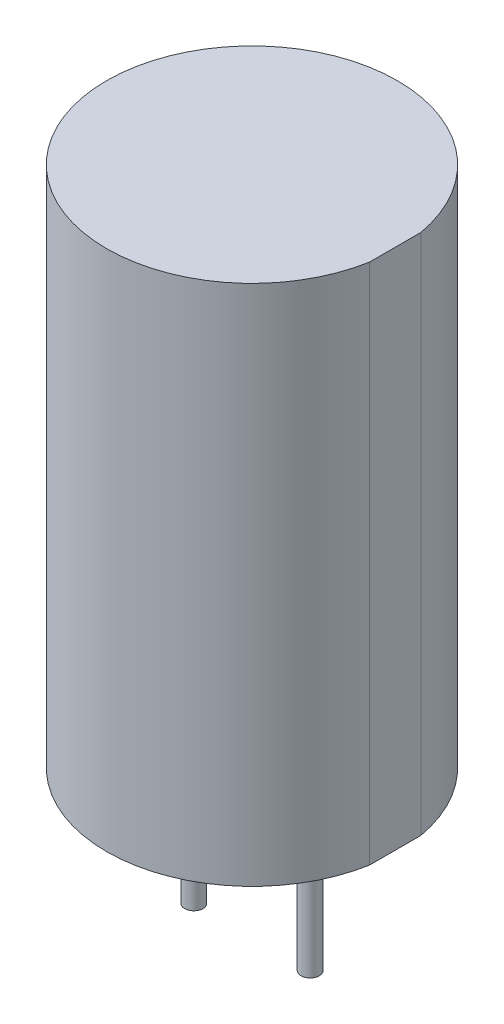
from build123d import *

# Parameters (mm, degrees)
BOSS_EXTRUDE1_DEPTH = 11.4
SKETCH2_R           = 0.2
BOSS_EXTRUDE2_DEPTH = 3.2


with BuildPart() as part:
    # Sketch1 → Boss-Extrude1 (new body)
    with BuildSketch(Plane(origin=(0, 0, 0), x_dir=(1, 0, 0), z_dir=(0, 1, 0))):
        with BuildLine():
            Line((3.125, 0.561248608), (3.125, -0.561248608))
            ThreePointArc((3.125, -0.561248608), (-3.175, 0), (3.125, 0.561248608))
        make_face()
    extrude(amount=BOSS_EXTRUDE1_DEPTH)

    # Sketch2 → Boss-Extrude2 (add)
    with BuildSketch(Plane.XZ):
        with Locations((-1.27, 0)):
            Circle(SKETCH2_R)
        with Locations((1.27, 0)):
            Circle(SKETCH2_R)
    extrude(amount=BOSS_EXTRUDE2_DEPTH)


solid = part.part
